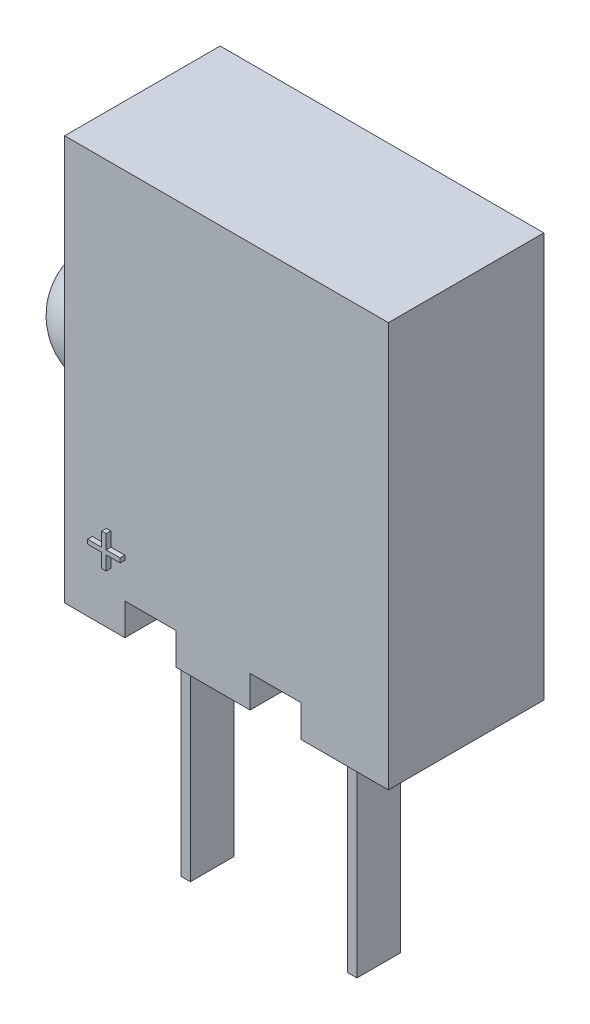
from build123d import *

# Parameters (mm, degrees)
SKETCH1_W          = 5.08
SKETCH1_H          = 6.35
EXTRUDE1_DEPTH     = 1.22
EXTRUDE3_DEPTH     = 0.075
CUT_EXTRUDE1_DEPTH = 0.5
SKETCH3_3_W        = 0.15
SKETCH3_3_H        = 0.686
EXTRUDE4_DEPTH     = 3.68
SKETCH4_W          = 0.012658227
SKETCH4_H          = 0.013291139
SKETCH4_W_2        = 0.012658228
CUT_EXTRUDE2_DEPTH = 0.01


with BuildPart() as part:
    # Sketch1 → Extrude1 (new body, symmetric)
    with BuildSketch(Plane.XY):
        Rectangle(SKETCH1_W, SKETCH1_H)
    extrude(amount=EXTRUDE1_DEPTH, both=True)

    # Sketch1_3 → Revolve1 (revolve)
    with BuildSketch(Plane.XY, mode=Mode.PRIVATE) as revolve1_sk:
        with BuildLine():
            Line((-2.54, -0.867409938), (-2.54, 0))
            Line((-2.54, 0), (-3.68, 0))
            ThreePointArc((-3.68, 0), (-3.324977064, -0.716240183), (-2.54, -0.867409938))
        make_face()
    revolve(revolve1_sk.sketch.rotate(Axis((-2.54, 0, 0), (-1, 0, 0)), 180), axis=Axis((-2.54, 0, 0), (-1, 0, 0)))  # turned: the seam where the file's is

    # Sketch2 → Extrude3 (add)
    with BuildSketch(Plane.XY.offset(1.22)):
        Polygon((-1.882939516, -2.052822621), (-1.882939516, -1.831668775), (-1.815631824, -1.831668775), (-1.815631824, -2.052822621), (-1.594477978, -2.052822621), (-1.594477978, -2.120130314), (-1.815631824, -2.120130314), (-1.815631824, -2.34128416), (-1.882939516, -2.34128416), (-1.882939516, -2.120130314), (-2.104093363, -2.120130314), (-2.104093363, -2.052822621), align=None)
    extrude(amount=EXTRUDE3_DEPTH)

    # Sketch3 → Cut-Extrude1 (cut)
    with BuildSketch(Plane.XZ.offset(3.175)):
        Polygon((-1.595, 1.22), (-1.595, 0.343), (-1.445, 0.343), (-1.445, -0.343), (-1.595, -0.343), (-1.595, -1.22), (-0.795, -1.22), (-0.795, 1.22), align=None)
        Polygon((1.17, 1.22), (0.37, 1.22), (0.37, -1.22), (1.17, -1.22), (1.17, -0.343), (1.02, -0.343), (1.02, 0.343), (1.17, 0.343), align=None)
    extrude(amount=-CUT_EXTRUDE1_DEPTH, mode=Mode.SUBTRACT)

    # Sketch3_3 → Extrude4 (add)
    with BuildSketch(Plane.XZ.offset(3.175)):
        with Locations((-1.52, 0)):
            Rectangle(SKETCH3_3_W, SKETCH3_3_H)
        with Locations((1.095, 0)):
            Rectangle(SKETCH3_3_W, SKETCH3_3_H)
    extrude(amount=EXTRUDE4_DEPTH)

    # Sketch4 → Cut-Extrude2 (cut)
    with BuildSketch(Plane.XZ.offset(3.175)):
        Polygon((-0.498575949, -0.945242807), (-0.510304589, -0.982584579), (-0.522676028, -0.982584579), (-0.530884098, -0.957416462), (-0.538647152, -0.982584579), (-0.551513054, -0.982584579), (-0.563132911, -0.945242807), (-0.550543908, -0.945242807), (-0.544046677, -0.9709845), (-0.535838608, -0.945242807), (-0.525089003, -0.945242807), (-0.51693038, -0.9709845), (-0.510522152, -0.945242807), align=None)
        Polygon((-0.431487342, -0.945242807), (-0.443215981, -0.982584579), (-0.455587421, -0.982584579), (-0.463795491, -0.957416462), (-0.471558544, -0.982584579), (-0.484424446, -0.982584579), (-0.496044304, -0.945242807), (-0.483455301, -0.945242807), (-0.47695807, -0.9709845), (-0.46875, -0.945242807), (-0.458000396, -0.945242807), (-0.449841772, -0.9709845), (-0.443433544, -0.945242807), align=None)
        Polygon((-0.364398734, -0.945242807), (-0.376127373, -0.982584579), (-0.388498813, -0.982584579), (-0.396706883, -0.957416462), (-0.404469937, -0.982584579), (-0.417335839, -0.982584579), (-0.428955696, -0.945242807), (-0.416366693, -0.945242807), (-0.409869462, -0.9709845), (-0.401661392, -0.945242807), (-0.390911788, -0.945242807), (-0.382753165, -0.9709845), (-0.376344937, -0.945242807), align=None)
        with Locations((-0.350474683, -0.97593901)):
            Rectangle(SKETCH4_W, SKETCH4_H)
        with BuildLine():
            add(Edge.make_bspline(
                [(-0.292246835, -0.966999136), (-0.29226508, -0.967610207), (-0.292300906, -0.968810146), (-0.292605765, -0.970563935), (-0.293102508, -0.972226288), (-0.293789567, -0.973807618), (-0.294683968, -0.975296927), (-0.295788763, -0.976687066), (-0.29707097, -0.978004466), (-0.298554075, -0.979207531), (-0.300194129, -0.980309719), (-0.301992917, -0.981258219), (-0.303932269, -0.98205646), (-0.306006562, -0.982725736), (-0.308229782, -0.983220026), (-0.310588547, -0.983581999), (-0.313085256, -0.983818664), (-0.314797045, -0.983839647), (-0.315674446, -0.983850402)],
                knots=[0, 0, 0, 0, 0.907352243, 1.781736951, 2.63548328, 3.47985091, 4.336556021, 5.208523475, 6.112432747, 7.062451073, 8.040435374, 9.043840564, 10.077958095, 11.152835584, 12.277940427, 13.457536469, 14.696825396, 16, 16, 16, 16], degree=3))
            add(Edge.make_bspline(
                [(-0.315674446, -0.983850402), (-0.316683574, -0.983838366), (-0.318638165, -0.983815054), (-0.321469928, -0.983600754), (-0.324103946, -0.983277684), (-0.326551804, -0.982794414), (-0.328854103, -0.982194031), (-0.331070737, -0.981548385), (-0.333211393, -0.980816177), (-0.334597938, -0.980266099), (-0.33528481, -0.979993598)],
                knots=[0, 0, 0, 0, 1.203215828, 2.33052265, 3.384689099, 4.366106119, 5.303329643, 6.221311756, 7.118865988, 8, 8, 8, 8], degree=3))
            Line((-0.33528481, -0.979993598), (-0.33528481, -0.968027617))
            Line((-0.33528481, -0.968027617), (-0.333860759, -0.968027617))
            add(Edge.make_bspline(
                [(-0.333860759, -0.968027617), (-0.333178102, -0.968568345), (-0.331816796, -0.969646625), (-0.32960018, -0.971027928), (-0.327276357, -0.972229009), (-0.324853621, -0.97321601), (-0.322405199, -0.974009172), (-0.31996751, -0.974555936), (-0.317584716, -0.97492961), (-0.316005432, -0.974969864), (-0.31522943, -0.974989642)],
                knots=[0, 0, 0, 0, 1.030622468, 2.055194264, 3.087043286, 4.125157485, 5.149848264, 6.130935704, 7.081611712, 8, 8, 8, 8], degree=3))
            add(Edge.make_bspline(
                [(-0.31522943, -0.974989642), (-0.315015042, -0.974989181), (-0.314556054, -0.974988192), (-0.313825291, -0.974924328), (-0.312999385, -0.97487654), (-0.312113131, -0.974772948), (-0.311214767, -0.974662018), (-0.310383567, -0.974474555), (-0.309628769, -0.974292121), (-0.309175509, -0.974108123), (-0.308959652, -0.974020497)],
                knots=[0, 0, 0, 0, 0.806402781, 1.726445712, 2.758724871, 3.919014682, 5.083870887, 6.16165551, 7.124521387, 8, 8, 8, 8], degree=3))
            add(Edge.make_bspline(
                [(-0.308959652, -0.974020497), (-0.30871987, -0.973906426), (-0.308248649, -0.973682252), (-0.307601849, -0.973277093), (-0.307018009, -0.972835361), (-0.306489323, -0.972352895), (-0.306052183, -0.97177002), (-0.305740249, -0.971065684), (-0.305567803, -0.970241175), (-0.305548291, -0.969653573), (-0.305537975, -0.969342886)],
                knots=[0, 0, 0, 0, 1.024747072, 2.013846092, 2.940605744, 3.850156746, 4.769278501, 5.73222711, 6.800942666, 8, 8, 8, 8], degree=3))
            add(Edge.make_bspline(
                [(-0.305537975, -0.969342886), (-0.305553897, -0.969070067), (-0.305585205, -0.968533626), (-0.305873802, -0.967766068), (-0.306328521, -0.967061484), (-0.306969316, -0.966427097), (-0.307765903, -0.96585233), (-0.308737095, -0.965361177), (-0.309862156, -0.964924584), (-0.310684191, -0.964715595), (-0.311115506, -0.96460594)],
                knots=[0, 0, 0, 0, 0.82557554, 1.623324704, 2.456147571, 3.35491006, 4.343819762, 5.427079081, 6.650009487, 8, 8, 8, 8], degree=3))
            add(Edge.make_bspline(
                [(-0.311115506, -0.96460594), (-0.312099819, -0.96438182), (-0.314119324, -0.963921995), (-0.317194237, -0.963352618), (-0.320258412, -0.962715188), (-0.322234795, -0.962111866), (-0.323200158, -0.961817174)],
                knots=[0, 0, 0, 0, 0.976100998, 2.002656142, 3.024398856, 4, 4, 4, 4], degree=3))
            add(Edge.make_bspline(
                [(-0.323200158, -0.961817174), (-0.323719417, -0.961640679), (-0.324730204, -0.961297115), (-0.326175959, -0.960716285), (-0.327506573, -0.96008137), (-0.32872643, -0.959403593), (-0.329826774, -0.958667323), (-0.330823908, -0.957896634), (-0.331705466, -0.957076614), (-0.332478869, -0.956206731), (-0.33314132, -0.95528138), (-0.333717513, -0.954308781), (-0.334208823, -0.953281071), (-0.334597842, -0.952195959), (-0.334910162, -0.951059132), (-0.335119652, -0.949870276), (-0.335269161, -0.948628711), (-0.335279523, -0.947781519), (-0.33528481, -0.947349215)],
                knots=[0, 0, 0, 0, 1.287047841, 2.5053592, 3.654260482, 4.74538952, 5.777514103, 6.75871007, 7.700244599, 8.599107454, 9.48590269, 10.366941872, 11.24940663, 12.154970331, 13.068988358, 14.012872203, 14.986013017, 16, 16, 16, 16], degree=3))
            add(Edge.make_bspline(
                [(-0.33528481, -0.947349215), (-0.335266159, -0.946771143), (-0.335229454, -0.945633507), (-0.33492874, -0.943968985), (-0.334415445, -0.942394616), (-0.333722413, -0.940892885), (-0.332808099, -0.939486342), (-0.331715702, -0.938147068), (-0.330403678, -0.936911272), (-0.328915118, -0.935761105), (-0.327271425, -0.934721406), (-0.325501934, -0.933806128), (-0.323617289, -0.933037802), (-0.321624516, -0.932400855), (-0.319515281, -0.93192352), (-0.317296665, -0.931564054), (-0.314959771, -0.931357463), (-0.31336406, -0.931331838), (-0.312549446, -0.931318756)],
                knots=[0, 0, 0, 0, 0.894990994, 1.761326291, 2.609044902, 3.454222546, 4.315366365, 5.200560057, 6.125081389, 7.100429509, 8.110379559, 9.133447974, 10.182136699, 11.259192205, 12.370181258, 13.528580438, 14.738335141, 16, 16, 16, 16], degree=3))
            add(Edge.make_bspline(
                [(-0.312549446, -0.931318756), (-0.311715099, -0.931329833), (-0.31004782, -0.931351967), (-0.30755715, -0.931541245), (-0.305079936, -0.931817401), (-0.302648724, -0.932242021), (-0.300302642, -0.932726137), (-0.298093085, -0.933275774), (-0.296053309, -0.933894527), (-0.294766482, -0.934371728), (-0.29414557, -0.934601984)],
                knots=[0, 0, 0, 0, 1.065407564, 2.129008667, 3.188544425, 4.247469455, 5.279542408, 6.247502114, 7.154394069, 8, 8, 8, 8], degree=3))
            Line((-0.29414557, -0.934601984), (-0.29414557, -0.945875718))
            Line((-0.29414557, -0.945875718), (-0.295559731, -0.945875718))
            add(Edge.make_bspline(
                [(-0.295559731, -0.945875718), (-0.296096483, -0.945476075), (-0.297191872, -0.944660492), (-0.299016673, -0.943609624), (-0.301000484, -0.942639578), (-0.303141297, -0.94179375), (-0.305371187, -0.941064746), (-0.307662566, -0.940554967), (-0.309975674, -0.940234113), (-0.311526526, -0.940197719), (-0.312302215, -0.940179516)],
                knots=[0, 0, 0, 0, 0.892265782, 1.820912499, 2.804518821, 3.836954028, 4.889985052, 5.931488012, 6.965393252, 8, 8, 8, 8], degree=3))
            add(Edge.make_bspline(
                [(-0.312302215, -0.940179516), (-0.312850018, -0.940190467), (-0.313948839, -0.940212434), (-0.315583435, -0.940404877), (-0.317203674, -0.940724303), (-0.318221015, -0.941132329), (-0.318730222, -0.941336557)],
                knots=[0, 0, 0, 0, 0.999122297, 2.004111588, 3.001004448, 4, 4, 4, 4], degree=3))
            add(Edge.make_bspline(
                [(-0.318730222, -0.941336557), (-0.318947086, -0.941437146), (-0.319380671, -0.941638258), (-0.319984442, -0.942028071), (-0.320544928, -0.942486243), (-0.32104272, -0.943012621), (-0.321464936, -0.943596798), (-0.32177445, -0.94423059), (-0.321961696, -0.94491253), (-0.321982869, -0.94538008), (-0.321993671, -0.945618598)],
                knots=[0, 0, 0, 0, 1.004925302, 2.009180302, 3.014392739, 4.04465309, 5.049195417, 6.035570224, 6.99785458, 8, 8, 8, 8], degree=3))
            add(Edge.make_bspline(
                [(-0.321993671, -0.945618598), (-0.321976452, -0.945937681), (-0.321943548, -0.946547419), (-0.321640256, -0.947405317), (-0.321147839, -0.948144534), (-0.320567536, -0.948641994), (-0.320008972, -0.948990713), (-0.319491142, -0.949245968), (-0.318886528, -0.949487647), (-0.318200905, -0.949736382), (-0.317432741, -0.949981975), (-0.316578462, -0.950219749), (-0.315637104, -0.950444397), (-0.314979167, -0.950587492), (-0.314636076, -0.950662111)],
                knots=[0, 0, 0, 0, 1.173816843, 2.243057204, 3.312297565, 4.415174738, 5.03266065, 5.73970059, 6.541434878, 7.433956553, 8.430083051, 9.515931566, 10.70464786, 12, 12, 12, 12], degree=3))
            add(Edge.make_bspline(
                [(-0.314636076, -0.950662111), (-0.313719615, -0.950849833), (-0.311922132, -0.951218019), (-0.309222519, -0.951774201), (-0.306470025, -0.952406881), (-0.30463445, -0.952982879), (-0.303678797, -0.95328276)],
                knots=[0, 0, 0, 0, 0.995749986, 1.952994291, 2.934271555, 4, 4, 4, 4], degree=3))
            add(Edge.make_bspline(
                [(-0.303678797, -0.95328276), (-0.303205553, -0.953442439), (-0.302279811, -0.953754798), (-0.300959038, -0.95429714), (-0.299734511, -0.954888185), (-0.298595376, -0.955499428), (-0.297564335, -0.956181036), (-0.296617723, -0.95688836), (-0.295776214, -0.957652414), (-0.295027239, -0.958458843), (-0.294368039, -0.959314059), (-0.293800557, -0.96023311), (-0.293318984, -0.961210375), (-0.292914918, -0.962246911), (-0.29262591, -0.963350445), (-0.292408881, -0.964513595), (-0.29226347, -0.965736253), (-0.292252442, -0.966573476), (-0.292246835, -0.966999136)],
                knots=[0, 0, 0, 0, 1.237386967, 2.420528625, 3.534815053, 4.605870898, 5.620827102, 6.594482803, 7.531295079, 8.432978826, 9.318460435, 10.202471551, 11.10474705, 12.014900263, 12.954095338, 13.926516828, 14.945802342, 16, 16, 16, 16], degree=3))
        make_face()
        with BuildLine():
            Line((-0.246044304, -0.982584579), (-0.25806962, -0.982584579))
            Line((-0.25806962, -0.982584579), (-0.25806962, -0.97866844))
            add(Edge.make_bspline(
                [(-0.25806962, -0.97866844), (-0.258616248, -0.979072774), (-0.259670138, -0.979852323), (-0.261257008, -0.980891705), (-0.262771368, -0.981783286), (-0.264232169, -0.982554362), (-0.265739846, -0.983149786), (-0.267353598, -0.983560714), (-0.26910473, -0.983811274), (-0.270318217, -0.983837069), (-0.270945411, -0.983850402)],
                knots=[0, 0, 0, 0, 1.150906677, 2.218931226, 3.20955724, 4.125565256, 5.012676028, 5.946647191, 6.938718366, 8, 8, 8, 8], degree=3))
            add(Edge.make_bspline(
                [(-0.270945411, -0.983850402), (-0.271453584, -0.983839037), (-0.272443143, -0.983816907), (-0.273881808, -0.983644538), (-0.275235464, -0.983375465), (-0.276493538, -0.982972537), (-0.277676211, -0.982485479), (-0.27875197, -0.981855935), (-0.279745815, -0.981126267), (-0.280647504, -0.980287799), (-0.281442813, -0.979327318), (-0.282136339, -0.978265943), (-0.282724245, -0.977098623), (-0.283195064, -0.97582294), (-0.28357253, -0.974443718), (-0.283834519, -0.972954114), (-0.283994809, -0.971360545), (-0.284010779, -0.97026298), (-0.284018987, -0.969698899)],
                knots=[0, 0, 0, 0, 1.108935798, 2.159418225, 3.158520219, 4.116592843, 5.038730546, 5.944611115, 6.829677354, 7.725673622, 8.624842385, 9.544872214, 10.487719724, 11.471363217, 12.50822837, 13.604887271, 14.769056852, 16, 16, 16, 16], degree=3))
            Line((-0.284018987, -0.969698899), (-0.284018987, -0.945242807))
            Line((-0.284018987, -0.945242807), (-0.271993671, -0.945242807))
            Line((-0.271993671, -0.945242807), (-0.271993671, -0.964032364))
            add(Edge.make_bspline(
                [(-0.271993671, -0.964032364), (-0.271992853, -0.964490599), (-0.271991288, -0.965367707), (-0.271950118, -0.966620611), (-0.271889668, -0.967754697), (-0.271820316, -0.968775711), (-0.271693807, -0.969699086), (-0.271504953, -0.970532167), (-0.27126954, -0.971291968), (-0.271037381, -0.971745319), (-0.270925633, -0.971963535)],
                knots=[0, 0, 0, 0, 1.361401701, 2.605856924, 3.723918663, 4.735739235, 5.645738665, 6.489217889, 7.27279937, 8, 8, 8, 8], degree=3))
            add(Edge.make_bspline(
                [(-0.270925633, -0.971963535), (-0.270810613, -0.972162859), (-0.270584494, -0.972554712), (-0.270124588, -0.973058286), (-0.269586597, -0.973476739), (-0.268951777, -0.973813061), (-0.268205237, -0.974054913), (-0.267339237, -0.974228287), (-0.266346229, -0.974335198), (-0.265641769, -0.97434928), (-0.265268987, -0.974356731)],
                knots=[0, 0, 0, 0, 0.849057291, 1.669173542, 2.503217716, 3.359509317, 4.311793648, 5.394940091, 6.621469141, 8, 8, 8, 8], degree=3))
            add(Edge.make_bspline(
                [(-0.265268987, -0.974356731), (-0.264998355, -0.974348002), (-0.264441916, -0.974330056), (-0.26358931, -0.974215091), (-0.262694796, -0.974034263), (-0.261437698, -0.973704751), (-0.259849625, -0.973115162), (-0.258667555, -0.972435761), (-0.25806962, -0.972092095)],
                knots=[0, 0, 0, 0, 0.638164724, 1.312110757, 2.025558264, 2.789159289, 4.375836335, 6, 6, 6, 6], degree=3))
            Line((-0.25806962, -0.972092095), (-0.25806962, -0.945242807))
            Line((-0.25806962, -0.945242807), (-0.246044304, -0.945242807))
            Line((-0.246044304, -0.945242807), (-0.246044304, -0.982584579))
        make_face()
        with BuildLine():
            Line((-0.197310127, -0.982584579), (-0.209335443, -0.982584579))
            Line((-0.209335443, -0.982584579), (-0.209335443, -0.963795022))
            add(Edge.make_bspline(
                [(-0.209335443, -0.963795022), (-0.209345605, -0.963029785), (-0.209365873, -0.961503579), (-0.209532663, -0.959625192), (-0.209699517, -0.958201296), (-0.209887929, -0.957283263), (-0.210103022, -0.956509095), (-0.210309245, -0.956066226), (-0.210403481, -0.955863851)],
                knots=[0, 0, 0, 0, 1.709235885, 3.408940626, 4.211008593, 4.910095588, 5.501954032, 6, 6, 6, 6], degree=3))
            add(Edge.make_bspline(
                [(-0.210403481, -0.955863851), (-0.210525695, -0.95566479), (-0.210765313, -0.955274503), (-0.211234221, -0.954768492), (-0.211782546, -0.954350385), (-0.212421907, -0.95401791), (-0.213164234, -0.953774961), (-0.214020571, -0.953581631), (-0.215013557, -0.953497351), (-0.215717241, -0.953479896), (-0.216089794, -0.953470655)],
                knots=[0, 0, 0, 0, 0.860145871, 1.686437142, 2.528070002, 3.393017362, 4.331453407, 5.402595683, 6.624848233, 8, 8, 8, 8], degree=3))
            add(Edge.make_bspline(
                [(-0.216089794, -0.953470655), (-0.216655739, -0.953498945), (-0.217811356, -0.953556712), (-0.219242001, -0.953913508), (-0.220405439, -0.954319656), (-0.22132825, -0.954706775), (-0.222286514, -0.955184087), (-0.222928226, -0.955547624), (-0.223259494, -0.955735291)],
                knots=[0, 0, 0, 0, 1.338419466, 2.732951426, 3.468143565, 4.254837763, 5.099104234, 6, 6, 6, 6], degree=3))
            Line((-0.223259494, -0.955735291), (-0.223259494, -0.982584579))
            Line((-0.223259494, -0.982584579), (-0.23528481, -0.982584579))
            Line((-0.23528481, -0.982584579), (-0.23528481, -0.945242807))
            Line((-0.23528481, -0.945242807), (-0.223259494, -0.945242807))
            Line((-0.223259494, -0.945242807), (-0.223259494, -0.949158946))
            add(Edge.make_bspline(
                [(-0.223259494, -0.949158946), (-0.222730875, -0.948755727), (-0.221701887, -0.947970838), (-0.220113511, -0.946954133), (-0.218578155, -0.946049205), (-0.217050894, -0.945293138), (-0.215488645, -0.944693838), (-0.21385483, -0.944286036), (-0.212146474, -0.944014562), (-0.210978137, -0.943989656), (-0.210383703, -0.943976984)],
                knots=[0, 0, 0, 0, 1.126064518, 2.191951536, 3.19307265, 4.144813015, 5.076393104, 6.021983703, 6.993610568, 8, 8, 8, 8], degree=3))
            add(Edge.make_bspline(
                [(-0.210383703, -0.943976984), (-0.209885567, -0.943989679), (-0.208913117, -0.944014461), (-0.207495737, -0.944169315), (-0.206160027, -0.944444648), (-0.204913889, -0.944843562), (-0.203742581, -0.945336369), (-0.202661603, -0.945952124), (-0.20166559, -0.946681344), (-0.200751305, -0.947511814), (-0.199936215, -0.948456794), (-0.199226472, -0.94951498), (-0.19864076, -0.950689344), (-0.198136344, -0.951962912), (-0.197769231, -0.953351798), (-0.197506006, -0.954847181), (-0.197330791, -0.956449772), (-0.197317153, -0.957557722), (-0.197310127, -0.958128487)],
                knots=[0, 0, 0, 0, 1.088441561, 2.124831547, 3.110816719, 4.062969431, 4.979391633, 5.88258537, 6.774334107, 7.671621258, 8.575503974, 9.49441354, 10.447872957, 11.437639084, 12.482478955, 13.580222388, 14.753440527, 16, 16, 16, 16], degree=3))
            Line((-0.197310127, -0.958128487), (-0.197310127, -0.982584579))
        make_face()
        Polygon((-0.149841772, -0.982584579), (-0.185917722, -0.982584579), (-0.185917722, -0.932584579), (-0.173259494, -0.932584579), (-0.173259494, -0.973090908), (-0.149841772, -0.973090908), align=None)
        Polygon((-0.106170886, -0.982584579), (-0.142246835, -0.982584579), (-0.142246835, -0.932584579), (-0.106170886, -0.932584579), (-0.106170886, -0.94207825), (-0.129588608, -0.94207825), (-0.129588608, -0.95093901), (-0.10806962, -0.95093901), (-0.10806962, -0.96043268), (-0.129588608, -0.96043268), (-0.129588608, -0.973090908), (-0.106170886, -0.973090908), align=None)
        with BuildLine():
            add(Edge.make_bspline(
                [(-0.047943038, -0.957634025), (-0.047952696, -0.95820787), (-0.047971822, -0.959344313), (-0.048119417, -0.961026716), (-0.04838243, -0.962659554), (-0.048722021, -0.964251678), (-0.049183274, -0.965791142), (-0.04972413, -0.967294931), (-0.050378953, -0.968747677), (-0.05113138, -0.970148395), (-0.051956116, -0.971484446), (-0.05284349, -0.97274455), (-0.05376638, -0.973936159), (-0.054761036, -0.975033606), (-0.055800627, -0.976054616), (-0.056888391, -0.977000023), (-0.058040924, -0.977851738), (-0.058844505, -0.978363181), (-0.05924644, -0.978618994)],
                knots=[0, 0, 0, 0, 1.105570398, 2.18947457, 3.250358341, 4.290584537, 5.323553275, 6.344225964, 7.367641686, 8.3905646, 9.405808457, 10.390761353, 11.358902336, 12.307789878, 13.241960776, 14.165076779, 15.082208636, 16, 16, 16, 16], degree=3))
            add(Edge.make_bspline(
                [(-0.05924644, -0.978618994), (-0.05986605, -0.978975079), (-0.061108433, -0.979689065), (-0.063100406, -0.980523131), (-0.065165965, -0.981227109), (-0.067345242, -0.981751204), (-0.069668417, -0.98211557), (-0.072165745, -0.982397096), (-0.074866309, -0.982547278), (-0.07673375, -0.982571862), (-0.077699763, -0.982584579)],
                knots=[0, 0, 0, 0, 0.896298978, 1.797171328, 2.70531317, 3.633678302, 4.606491125, 5.655688921, 6.787306437, 8, 8, 8, 8], degree=3))
            Line((-0.077699763, -0.982584579), (-0.095411392, -0.982584579))
            Line((-0.095411392, -0.982584579), (-0.095411392, -0.932584579))
            Line((-0.095411392, -0.932584579), (-0.077195411, -0.932584579))
            add(Edge.make_bspline(
                [(-0.077195411, -0.932584579), (-0.076206049, -0.932592927), (-0.074297693, -0.932609029), (-0.071542484, -0.932817013), (-0.068993294, -0.933116773), (-0.066651005, -0.933580119), (-0.064496802, -0.934134444), (-0.06253129, -0.934815962), (-0.060725346, -0.935565098), (-0.059635932, -0.936201972), (-0.059107991, -0.936510608)],
                knots=[0, 0, 0, 0, 1.267192274, 2.444256634, 3.537982003, 4.553396635, 5.500903572, 6.385021601, 7.217363933, 8, 8, 8, 8], degree=3))
            add(Edge.make_bspline(
                [(-0.059107991, -0.936510608), (-0.058682514, -0.936778878), (-0.057836452, -0.937312335), (-0.056635844, -0.938203261), (-0.055521131, -0.939181299), (-0.054456879, -0.940207209), (-0.053466972, -0.941308652), (-0.052545365, -0.942478004), (-0.051693482, -0.943717058), (-0.050914404, -0.945021768), (-0.050204362, -0.946386888), (-0.049608322, -0.94782306), (-0.049088641, -0.949314497), (-0.0486656, -0.950863967), (-0.048337435, -0.952472661), (-0.048114393, -0.954141401), (-0.047972676, -0.955867996), (-0.047953001, -0.957040392), (-0.047943038, -0.957634025)],
                knots=[0, 0, 0, 0, 0.964043478, 1.917004671, 2.862223898, 3.805158963, 4.749279098, 5.698713747, 6.657523689, 7.629652222, 8.610369353, 9.604453025, 10.607693792, 11.636365947, 12.681120053, 13.752669011, 14.862083412, 16, 16, 16, 16], degree=3))
        make_face()
        with BuildLine():
            add(Edge.make_bspline(
                [(-0.061234177, -0.957554911), (-0.061239413, -0.957152555), (-0.061249682, -0.956363309), (-0.061343844, -0.955205221), (-0.061479137, -0.954092196), (-0.061673704, -0.95302038), (-0.061943921, -0.951995306), (-0.062260011, -0.951014521), (-0.062623556, -0.95007506), (-0.063064021, -0.94918623), (-0.063550934, -0.948332061), (-0.064124655, -0.947539298), (-0.064748831, -0.946782856), (-0.065437973, -0.946068863), (-0.066209443, -0.945415916), (-0.067039494, -0.944800877), (-0.067939673, -0.944236714), (-0.068576167, -0.94390669), (-0.068898339, -0.943739642)],
                knots=[0, 0, 0, 0, 1.152052275, 2.259818351, 3.325348653, 4.362224493, 5.376551665, 6.358740615, 7.312387502, 8.258104984, 9.197203025, 10.124507262, 11.056413058, 12.004389423, 12.961766972, 13.947352551, 14.961020569, 16, 16, 16, 16], degree=3))
            add(Edge.make_bspline(
                [(-0.068898339, -0.943739642), (-0.069235787, -0.943586286), (-0.069904635, -0.943282324), (-0.070940046, -0.942916728), (-0.071984738, -0.94263031), (-0.073085537, -0.942414881), (-0.074320417, -0.942253916), (-0.075783208, -0.942155286), (-0.077511163, -0.942084202), (-0.07875452, -0.942080326), (-0.079420491, -0.94207825)],
                knots=[0, 0, 0, 0, 0.826967603, 1.639107464, 2.447640171, 3.242670507, 4.14065217, 5.225198036, 6.513753944, 8, 8, 8, 8], degree=3))
            Line((-0.079420491, -0.94207825), (-0.082753165, -0.94207825))
            Line((-0.082753165, -0.94207825), (-0.082753165, -0.973090908))
            Line((-0.082753165, -0.973090908), (-0.079420491, -0.973090908))
            add(Edge.make_bspline(
                [(-0.079420491, -0.973090908), (-0.079041387, -0.973088535), (-0.078309504, -0.973083954), (-0.077251385, -0.973062398), (-0.076268477, -0.973039041), (-0.075366074, -0.972980522), (-0.074539902, -0.972945272), (-0.073796829, -0.972853436), (-0.073128354, -0.972786199), (-0.072342113, -0.972647338), (-0.07141452, -0.97244435), (-0.070331126, -0.972102771), (-0.069260776, -0.971677984), (-0.068566501, -0.971335445), (-0.068215981, -0.971162506)],
                knots=[0, 0, 0, 0, 1.186805873, 2.291202465, 3.313317863, 4.264127762, 5.122212376, 5.900577546, 6.607154111, 7.224697658, 8.398873738, 9.57716935, 10.776782771, 12, 12, 12, 12], degree=3))
            add(Edge.make_bspline(
                [(-0.068215981, -0.971162506), (-0.067923424, -0.970991748), (-0.067346464, -0.970654989), (-0.066534694, -0.970087963), (-0.065780899, -0.969484058), (-0.06508266, -0.968839988), (-0.064451867, -0.968145295), (-0.063873824, -0.967415562), (-0.06337113, -0.966635402), (-0.062751503, -0.965540989), (-0.062127958, -0.96402861), (-0.061611758, -0.962042233), (-0.061292185, -0.959862777), (-0.061254008, -0.958343907), (-0.061234177, -0.957554911)],
                knots=[0, 0, 0, 0, 0.755237594, 1.489427721, 2.205882609, 2.908165467, 3.605466573, 4.296695275, 4.981837198, 5.673065901, 7.099889822, 8.61390339, 10.241051878, 12, 12, 12, 12], degree=3))
        make_face(mode=Mode.SUBTRACT)
        with Locations((-0.032120253, -0.97593901)):
            Rectangle(SKETCH4_W_2, SKETCH4_H)
        with BuildLine():
            add(Edge.make_bspline(
                [(0.005201741, -0.983850402), (0.004406682, -0.9838395), (0.00284611, -0.983818102), (0.000560466, -0.983579588), (-0.001622217, -0.98322094), (-0.003695028, -0.98270978), (-0.0056503, -0.982039521), (-0.007477775, -0.981204518), (-0.009186111, -0.98022092), (-0.010217071, -0.979428472), (-0.010729826, -0.979034342)],
                knots=[0, 0, 0, 0, 1.123701398, 2.205645569, 3.245398653, 4.249180969, 5.220497262, 6.163202923, 7.086456062, 8, 8, 8, 8], degree=3))
            add(Edge.make_bspline(
                [(-0.010729826, -0.979034342), (-0.011205643, -0.978606925), (-0.012155438, -0.977753745), (-0.013389252, -0.976268473), (-0.01444829, -0.974623987), (-0.015354417, -0.97282816), (-0.016070393, -0.970868218), (-0.016566661, -0.968743271), (-0.016880463, -0.966464606), (-0.016913438, -0.964890503), (-0.01693038, -0.96408181)],
                knots=[0, 0, 0, 0, 0.916342154, 1.829140869, 2.758848968, 3.716597128, 4.708179637, 5.743612459, 6.840783343, 8, 8, 8, 8], degree=3))
            add(Edge.make_bspline(
                [(-0.01693038, -0.96408181), (-0.016911, -0.963230197), (-0.016873438, -0.961579657), (-0.016541558, -0.959193563), (-0.016006752, -0.956984722), (-0.015237973, -0.954958768), (-0.014272752, -0.953112173), (-0.013140506, -0.951426255), (-0.011830243, -0.949904793), (-0.010826674, -0.949032073), (-0.010324367, -0.94859526)],
                knots=[0, 0, 0, 0, 1.171797512, 2.271099083, 3.308930235, 4.294129479, 5.24602549, 6.17106565, 7.084581485, 8, 8, 8, 8], degree=3))
            add(Edge.make_bspline(
                [(-0.010324367, -0.94859526), (-0.009811475, -0.94821087), (-0.008779496, -0.947437449), (-0.007079726, -0.946490042), (-0.00527362, -0.945687784), (-0.003358062, -0.945064841), (-0.001367802, -0.944590572), (0.000664968, -0.944227086), (0.002738151, -0.944017074), (0.004133244, -0.943990412), (0.004835839, -0.943976984)],
                knots=[0, 0, 0, 0, 0.952097844, 1.915695341, 2.885641886, 3.886921822, 4.905719434, 5.925883802, 6.95543633, 8, 8, 8, 8], degree=3))
            add(Edge.make_bspline(
                [(0.004835839, -0.943976984), (0.005459202, -0.943985466), (0.006684945, -0.944002144), (0.008485412, -0.944163473), (0.010209705, -0.944428555), (0.011858361, -0.944800352), (0.013444935, -0.945246751), (0.014974671, -0.945762392), (0.016457079, -0.946331362), (0.017407418, -0.94677347), (0.017879747, -0.946993203)],
                knots=[0, 0, 0, 0, 1.107671842, 2.178058178, 3.209662749, 4.206063564, 5.179815947, 6.137646632, 7.07438927, 8, 8, 8, 8], degree=3))
            Line((0.017879747, -0.946993203), (0.017879747, -0.957268123))
            Line((0.017879747, -0.957268123), (0.016208465, -0.957268123))
            add(Edge.make_bspline(
                [(0.016208465, -0.957268123), (0.015959081, -0.95705901), (0.015418113, -0.956605398), (0.014517437, -0.955904892), (0.013450682, -0.955129609), (0.012625078, -0.954686607), (0.012183544, -0.95444969)],
                knots=[0, 0, 0, 0, 0.792878214, 1.719922066, 2.780612869, 4, 4, 4, 4], degree=3))
            add(Edge.make_bspline(
                [(0.012183544, -0.95444969), (0.011719715, -0.954228256), (0.0107662, -0.953773044), (0.009486212, -0.953363272), (0.008391696, -0.953074004), (0.007485754, -0.952947599), (0.006519044, -0.952852425), (0.005851409, -0.952842727), (0.005508307, -0.952837744)],
                knots=[0, 0, 0, 0, 1.33256682, 2.739414054, 3.480190821, 4.267897792, 5.109861573, 6, 6, 6, 6], degree=3))
            add(Edge.make_bspline(
                [(0.005508307, -0.952837744), (0.005125533, -0.952847523), (0.004383734, -0.952866476), (0.003302933, -0.953004937), (0.002293895, -0.953244305), (0.00134169, -0.95356351), (0.000472317, -0.95401163), (-0.000348948, -0.954517764), (-0.001086185, -0.955145018), (-0.001757159, -0.955853888), (-0.002350901, -0.956649145), (-0.002864277, -0.957512389), (-0.00330564, -0.958441335), (-0.003656587, -0.959440289), (-0.003935342, -0.96050522), (-0.004130125, -0.961636625), (-0.004251014, -0.962836424), (-0.004264985, -0.963659572), (-0.004272152, -0.96408181)],
                knots=[0, 0, 0, 0, 1.087094245, 2.106738054, 3.087824582, 4.029427112, 4.95060567, 5.859714611, 6.763601524, 7.690850518, 8.627131371, 9.576106403, 10.539384251, 11.543302637, 12.578856349, 13.662518017, 14.800975475, 16, 16, 16, 16], degree=3))
            add(Edge.make_bspline(
                [(-0.004272152, -0.96408181), (-0.004264765, -0.964513888), (-0.004250412, -0.965353395), (-0.004133655, -0.9665742), (-0.003925709, -0.967714916), (-0.003640085, -0.968777576), (-0.003277911, -0.969760585), (-0.002825352, -0.970659283), (-0.002307174, -0.971487687), (-0.001684895, -0.972218993), (-0.001002953, -0.972877153), (-0.000245508, -0.973445221), (0.000584112, -0.973919293), (0.001475202, -0.974321525), (0.002441723, -0.974610724), (0.003469991, -0.97482907), (0.004564769, -0.974973348), (0.005319945, -0.97498413), (0.005706092, -0.974989642)],
                knots=[0, 0, 0, 0, 1.230336593, 2.390482092, 3.487897344, 4.52859895, 5.520747884, 6.465347575, 7.38981449, 8.296085817, 9.192433006, 10.084246191, 10.984321635, 11.908883871, 12.862027947, 13.850751296, 14.901019963, 16, 16, 16, 16], degree=3))
            add(Edge.make_bspline(
                [(0.005706092, -0.974989642), (0.006069013, -0.974985531), (0.006776514, -0.974977515), (0.007805725, -0.974869482), (0.008782684, -0.974729819), (0.009699957, -0.97450918), (0.010552082, -0.974241738), (0.011334908, -0.973956325), (0.012041212, -0.973654185), (0.012471879, -0.973420377), (0.012678006, -0.973308472)],
                knots=[0, 0, 0, 0, 1.200879421, 2.341068892, 3.423000803, 4.465923194, 5.460027553, 6.378409259, 7.223869634, 8, 8, 8, 8], degree=3))
            add(Edge.make_bspline(
                [(0.012678006, -0.973308472), (0.013032184, -0.973094629), (0.013712871, -0.972683649), (0.01462543, -0.971973419), (0.015447493, -0.971270199), (0.015959546, -0.970791815), (0.016208465, -0.970559263)],
                knots=[0, 0, 0, 0, 1.105932972, 2.12546697, 3.088749538, 4, 4, 4, 4], degree=3))
            Line((0.016208465, -0.970559263), (0.017879747, -0.970559263))
            Line((0.017879747, -0.970559263), (0.017879747, -0.980913297))
            add(Edge.make_bspline(
                [(0.017879747, -0.980913297), (0.017407058, -0.981132069), (0.016461568, -0.981569663), (0.015004179, -0.982146239), (0.013507558, -0.982632678), (0.011981943, -0.983078851), (0.010397127, -0.983427949), (0.008738453, -0.983672564), (0.0069978, -0.983823433), (0.005808592, -0.98384129), (0.005201741, -0.983850402)],
                knots=[0, 0, 0, 0, 0.952024047, 1.90427691, 2.862762905, 3.827874523, 4.80891974, 5.826446878, 6.890837857, 8, 8, 8, 8], degree=3))
        make_face()
        with BuildLine():
            add(Edge.make_bspline(
                [(0.064082278, -0.963933472), (0.064069819, -0.964685887), (0.064045531, -0.966152548), (0.063777427, -0.968288958), (0.063365695, -0.970304179), (0.062799033, -0.972204598), (0.062040106, -0.97397612), (0.061118899, -0.975624097), (0.060032104, -0.977150189), (0.058786945, -0.978545302), (0.057386202, -0.979794398), (0.055849319, -0.980892495), (0.054164386, -0.981796019), (0.052360013, -0.982559293), (0.050415359, -0.983137344), (0.048335812, -0.983546319), (0.046127057, -0.983813485), (0.044607875, -0.983837891), (0.043829114, -0.983850402)],
                knots=[0, 0, 0, 0, 1.120122129, 2.18341868, 3.201215738, 4.181270334, 5.131540819, 6.065757527, 6.988093576, 7.916512302, 8.844931028, 9.778115023, 10.722851943, 11.686686084, 12.691660064, 13.738321946, 14.84062285, 16, 16, 16, 16], degree=3))
            add(Edge.make_bspline(
                [(0.043829114, -0.983850402), (0.04305034, -0.983837932), (0.041531131, -0.983813606), (0.039322563, -0.983545871), (0.037245454, -0.983139512), (0.035303128, -0.982554895), (0.033495972, -0.98179885), (0.031809059, -0.980892129), (0.030271968, -0.979794502), (0.028871367, -0.978545247), (0.027625848, -0.977150305), (0.026540346, -0.97562369), (0.025614876, -0.973978793), (0.02487468, -0.972200156), (0.024288414, -0.970306552), (0.023882025, -0.968288553), (0.023612366, -0.966152657), (0.023588297, -0.964685925), (0.023575949, -0.963933472)],
                knots=[0, 0, 0, 0, 1.159424321, 2.261770074, 3.308474541, 4.308788811, 5.277191138, 6.221966496, 7.15518846, 8.08364496, 9.01210146, 9.934475036, 10.868729753, 11.817121636, 12.798654016, 13.816492484, 14.879832297, 16, 16, 16, 16], degree=3))
            add(Edge.make_bspline(
                [(0.023575949, -0.963933472), (0.023588511, -0.96317776), (0.023613053, -0.961701254), (0.023880738, -0.959551818), (0.024289747, -0.957521493), (0.024869763, -0.955617336), (0.0256279, -0.953841536), (0.026548412, -0.952190484), (0.027646646, -0.950667197), (0.028901395, -0.949272321), (0.030307292, -0.94802413), (0.031854258, -0.946937677), (0.033530217, -0.946019349), (0.035333817, -0.945258432), (0.037277095, -0.94469115), (0.039345566, -0.94428236), (0.041544263, -0.944013324), (0.043053632, -0.943989318), (0.043829114, -0.943976984)],
                knots=[0, 0, 0, 0, 1.124034801, 2.196132384, 3.217834281, 4.203147447, 5.152578239, 6.085969439, 7.010345409, 7.941219594, 8.872481455, 9.802010446, 10.748267785, 11.711250247, 12.709230373, 13.754967386, 14.846549946, 16, 16, 16, 16], degree=3))
            add(Edge.make_bspline(
                [(0.043829114, -0.943976984), (0.044614486, -0.94398934), (0.046143574, -0.944013397), (0.048365238, -0.944281566), (0.050452303, -0.94468783), (0.052401108, -0.945271864), (0.054213112, -0.946023499), (0.0558867, -0.946950973), (0.057429179, -0.948038148), (0.058813311, -0.949303062), (0.06005519, -0.950700539), (0.061136368, -0.952229379), (0.062054106, -0.953883167), (0.062791978, -0.955664104), (0.063379079, -0.95756042), (0.063789285, -0.959577634), (0.064042361, -0.961715087), (0.064068741, -0.963181159), (0.064082278, -0.963933472)],
                knots=[0, 0, 0, 0, 1.167473013, 2.273023816, 3.322954552, 4.326451713, 5.293391623, 6.234801871, 7.166614545, 8.093305908, 9.017100806, 9.942078766, 10.872536262, 11.824015763, 12.804065898, 13.820367293, 14.881523901, 16, 16, 16, 16], degree=3))
        make_face()
        with BuildLine():
            add(Edge.make_bspline(
                [(0.049228639, -0.973179911), (0.049406012, -0.972929815), (0.049766987, -0.972420839), (0.050204957, -0.971573243), (0.050584784, -0.970657609), (0.050894127, -0.969644468), (0.051149198, -0.968495579), (0.051300008, -0.967167113), (0.051416415, -0.96564967), (0.051421405, -0.964573266), (0.051424051, -0.964002696)],
                knots=[0, 0, 0, 0, 0.765094823, 1.557058493, 2.376706509, 3.238810155, 4.199844458, 5.312104478, 6.575226644, 8, 8, 8, 8], degree=3))
            add(Edge.make_bspline(
                [(0.051424051, -0.964002696), (0.051415206, -0.963465255), (0.051398261, -0.962435577), (0.051305076, -0.960955696), (0.051130739, -0.959613983), (0.0508818, -0.958405284), (0.050576915, -0.957319941), (0.050213947, -0.956348759), (0.049794688, -0.955489458), (0.049451955, -0.954986842), (0.049287975, -0.954746367)],
                knots=[0, 0, 0, 0, 1.337076348, 2.561692668, 3.686680134, 4.69989255, 5.629188848, 6.488203485, 7.276684665, 8, 8, 8, 8], degree=3))
            add(Edge.make_bspline(
                [(0.049287975, -0.954746367), (0.049118688, -0.954527449), (0.048788063, -0.95409989), (0.048209186, -0.953548073), (0.047568945, -0.953109098), (0.046878522, -0.952774766), (0.046158168, -0.952518011), (0.045405106, -0.95233999), (0.044626826, -0.952229409), (0.044096487, -0.95221307), (0.043829114, -0.952204832)],
                knots=[0, 0, 0, 0, 1.058499091, 2.067300666, 3.047512573, 4.018335651, 4.996351322, 5.969796037, 6.97646375, 8, 8, 8, 8], degree=3))
            add(Edge.make_bspline(
                [(0.043829114, -0.952204832), (0.043565163, -0.952210347), (0.043048883, -0.952221134), (0.042297344, -0.952310393), (0.041589518, -0.952460392), (0.040916935, -0.952662485), (0.040274361, -0.952968173), (0.039658723, -0.953392582), (0.039051029, -0.953930872), (0.038681865, -0.954356039), (0.038488924, -0.95457825)],
                knots=[0, 0, 0, 0, 1.04189444, 2.037910168, 2.982338511, 3.896140384, 4.804271323, 5.778885192, 6.839150358, 8, 8, 8, 8], degree=3))
            add(Edge.make_bspline(
                [(0.038488924, -0.95457825), (0.038321207, -0.954815084), (0.037969212, -0.955312138), (0.037544618, -0.956172323), (0.037159968, -0.957145068), (0.036820324, -0.958240636), (0.036554731, -0.959474406), (0.036375637, -0.960853712), (0.036253297, -0.96237868), (0.036240739, -0.963445333), (0.036234177, -0.964002696)],
                knots=[0, 0, 0, 0, 0.70629823, 1.482341141, 2.329662943, 3.254583898, 4.274063958, 5.401087491, 6.641978366, 8, 8, 8, 8], degree=3))
            add(Edge.make_bspline(
                [(0.036234177, -0.964002696), (0.036237147, -0.964504066), (0.0362429, -0.965475132), (0.036363998, -0.966876297), (0.036507411, -0.96818052), (0.036750696, -0.969374546), (0.037036615, -0.970467134), (0.037410637, -0.971442931), (0.037822307, -0.972320468), (0.038172484, -0.972834337), (0.038340585, -0.973081019)],
                knots=[0, 0, 0, 0, 1.270983191, 2.461674417, 3.564986371, 4.596265355, 5.549463796, 6.425202083, 7.244022889, 8, 8, 8, 8], degree=3))
            add(Edge.make_bspline(
                [(0.038340585, -0.973081019), (0.038510767, -0.973289406), (0.03884629, -0.973700255), (0.039420187, -0.974238326), (0.040054174, -0.974675604), (0.040728983, -0.975037099), (0.041462279, -0.97530429), (0.042242421, -0.975489257), (0.043071146, -0.975598827), (0.043637589, -0.975614512), (0.043928006, -0.975622554)],
                knots=[0, 0, 0, 0, 1.010886179, 1.993025998, 2.945391046, 3.898964935, 4.863589088, 5.87059323, 6.908247091, 8, 8, 8, 8], degree=3))
            add(Edge.make_bspline(
                [(0.043928006, -0.975622554), (0.04443182, -0.975596293), (0.045430724, -0.975544227), (0.046638434, -0.975186023), (0.047539263, -0.974758534), (0.048166662, -0.974328829), (0.048735817, -0.973798445), (0.04906225, -0.973388745), (0.049228639, -0.973179911)],
                knots=[0, 0, 0, 0, 1.49343762, 2.961012893, 3.700518105, 4.446788108, 5.208294864, 6, 6, 6, 6], degree=3))
        make_face(mode=Mode.SUBTRACT)
        with BuildLine():
            Line((0.109651899, -0.955735291), (0.109651899, -0.982584579))
            Line((0.109651899, -0.982584579), (0.097626582, -0.982584579))
            Line((0.097626582, -0.982584579), (0.097626582, -0.963656573))
            add(Edge.make_bspline(
                [(0.097626582, -0.963656573), (0.097623449, -0.963211573), (0.097617438, -0.962357791), (0.097606181, -0.961127626), (0.097548496, -0.960003954), (0.097500219, -0.958980287), (0.097400877, -0.958052094), (0.097262042, -0.95721224), (0.097047614, -0.956460742), (0.096843901, -0.956010184), (0.09674644, -0.955794627)],
                knots=[0, 0, 0, 0, 1.33997484, 2.570892857, 3.703483919, 4.727540125, 5.655929516, 6.512630168, 7.288405602, 8, 8, 8, 8], degree=3))
            add(Edge.make_bspline(
                [(0.09674644, -0.955794627), (0.096641477, -0.955601943), (0.096433415, -0.955219996), (0.095999392, -0.954736066), (0.095495238, -0.954330744), (0.094905157, -0.954010016), (0.094215815, -0.953760935), (0.093408255, -0.953586262), (0.092476326, -0.953496061), (0.091815182, -0.953479443), (0.091465585, -0.953470655)],
                knots=[0, 0, 0, 0, 0.859345536, 1.703436662, 2.532498256, 3.390183975, 4.328249457, 5.402602062, 6.626559876, 8, 8, 8, 8], degree=3))
            add(Edge.make_bspline(
                [(0.091465585, -0.953470655), (0.091171916, -0.953482353), (0.090581928, -0.953505853), (0.089699871, -0.953628325), (0.088836066, -0.953876016), (0.087726523, -0.954294871), (0.086427091, -0.954906968), (0.085443126, -0.955465699), (0.084968354, -0.955735291)],
                knots=[0, 0, 0, 0, 0.759382397, 1.525614786, 2.294447385, 3.076151307, 4.589219126, 6, 6, 6, 6], degree=3))
            Line((0.084968354, -0.955735291), (0.084968354, -0.982584579))
            Line((0.084968354, -0.982584579), (0.072943038, -0.982584579))
            Line((0.072943038, -0.982584579), (0.072943038, -0.945242807))
            Line((0.072943038, -0.945242807), (0.084968354, -0.945242807))
            Line((0.084968354, -0.945242807), (0.084968354, -0.949158946))
            add(Edge.make_bspline(
                [(0.084968354, -0.949158946), (0.085478899, -0.948768256), (0.086470169, -0.948009695), (0.087976807, -0.946986031), (0.089453253, -0.946108238), (0.090899597, -0.945334291), (0.092376436, -0.944714483), (0.093925638, -0.944293013), (0.095547283, -0.944027477), (0.096656387, -0.94399402), (0.097221123, -0.943976984)],
                knots=[0, 0, 0, 0, 1.136109262, 2.205863928, 3.217041414, 4.170849475, 5.103496751, 6.040664374, 7.002340634, 8, 8, 8, 8], degree=3))
            add(Edge.make_bspline(
                [(0.097221123, -0.943976984), (0.097822741, -0.943992861), (0.09899856, -0.944023892), (0.100704581, -0.944358462), (0.102312304, -0.944860996), (0.103791113, -0.945605405), (0.105151212, -0.946526131), (0.106357792, -0.947654501), (0.107402739, -0.948988122), (0.107948515, -0.949990736), (0.108227848, -0.950503883)],
                knots=[0, 0, 0, 0, 1.065971563, 2.0833675, 3.072814207, 4.045738768, 5.009267307, 5.977487593, 6.964858173, 8, 8, 8, 8], degree=3))
            add(Edge.make_bspline(
                [(0.108227848, -0.950503883), (0.108818891, -0.950015401), (0.109970718, -0.949063443), (0.111747526, -0.947792132), (0.113487066, -0.946664853), (0.115207326, -0.945710441), (0.116907548, -0.944935164), (0.118598801, -0.94438817), (0.120272016, -0.944041988), (0.121385558, -0.943998444), (0.121934335, -0.943976984)],
                knots=[0, 0, 0, 0, 1.188147474, 2.315470194, 3.384102413, 4.399459064, 5.362307068, 6.27522031, 7.149990929, 8, 8, 8, 8], degree=3))
            add(Edge.make_bspline(
                [(0.121934335, -0.943976984), (0.122425961, -0.943988682), (0.123382532, -0.944011442), (0.12477381, -0.944178949), (0.126071903, -0.944464814), (0.127281039, -0.944859279), (0.128397608, -0.945375433), (0.129420824, -0.946013589), (0.130357324, -0.946756489), (0.131193283, -0.94761732), (0.131936246, -0.948579386), (0.132584365, -0.94964687), (0.133123442, -0.950816912), (0.133572493, -0.952084166), (0.133914549, -0.953452258), (0.134159583, -0.954923716), (0.134308689, -0.956493681), (0.134326374, -0.957574355), (0.134335443, -0.958128487)],
                knots=[0, 0, 0, 0, 1.099528869, 2.139389204, 3.128691273, 4.06836032, 4.978849901, 5.872980696, 6.759662307, 7.646067956, 8.55014577, 9.473266406, 10.433198647, 11.426668526, 12.476415665, 13.583140093, 14.760718182, 16, 16, 16, 16], degree=3))
            Line((0.134335443, -0.958128487), (0.134335443, -0.982584579))
            Line((0.134335443, -0.982584579), (0.122310127, -0.982584579))
            Line((0.122310127, -0.982584579), (0.122310127, -0.963656573))
            add(Edge.make_bspline(
                [(0.122310127, -0.963656573), (0.122307271, -0.963208265), (0.122301792, -0.962347867), (0.122286951, -0.96111469), (0.122242133, -0.959990782), (0.12220186, -0.958970836), (0.12211755, -0.958044769), (0.121974033, -0.957208945), (0.12175897, -0.95646295), (0.121563024, -0.956010488), (0.121469541, -0.955794627)],
                knots=[0, 0, 0, 0, 1.350843832, 2.592553583, 3.715618503, 4.739861077, 5.667890227, 6.515410335, 7.291728161, 8, 8, 8, 8], degree=3))
            add(Edge.make_bspline(
                [(0.121469541, -0.955794627), (0.121367852, -0.955602124), (0.121166523, -0.955220996), (0.120741967, -0.9547335), (0.120236049, -0.954328236), (0.119637586, -0.95401041), (0.118938757, -0.953760964), (0.118121349, -0.953586382), (0.117176351, -0.953495734), (0.116505323, -0.953479351), (0.11614913, -0.953470655)],
                knots=[0, 0, 0, 0, 0.84645005, 1.675850114, 2.498752818, 3.361341904, 4.304511378, 5.383432037, 6.611077598, 8, 8, 8, 8], degree=3))
            add(Edge.make_bspline(
                [(0.11614913, -0.953470655), (0.115648833, -0.95349488), (0.11463927, -0.953543763), (0.113395128, -0.953895249), (0.112387032, -0.95431007), (0.111539163, -0.954696685), (0.110618783, -0.955181896), (0.109983701, -0.955545384), (0.109651899, -0.955735291)],
                knots=[0, 0, 0, 0, 1.291070249, 2.605286939, 3.312383926, 4.109045945, 5.012060117, 6, 6, 6, 6], degree=3))
        make_face()
    extrude(amount=-CUT_EXTRUDE2_DEPTH, mode=Mode.SUBTRACT)


solid = part.part
